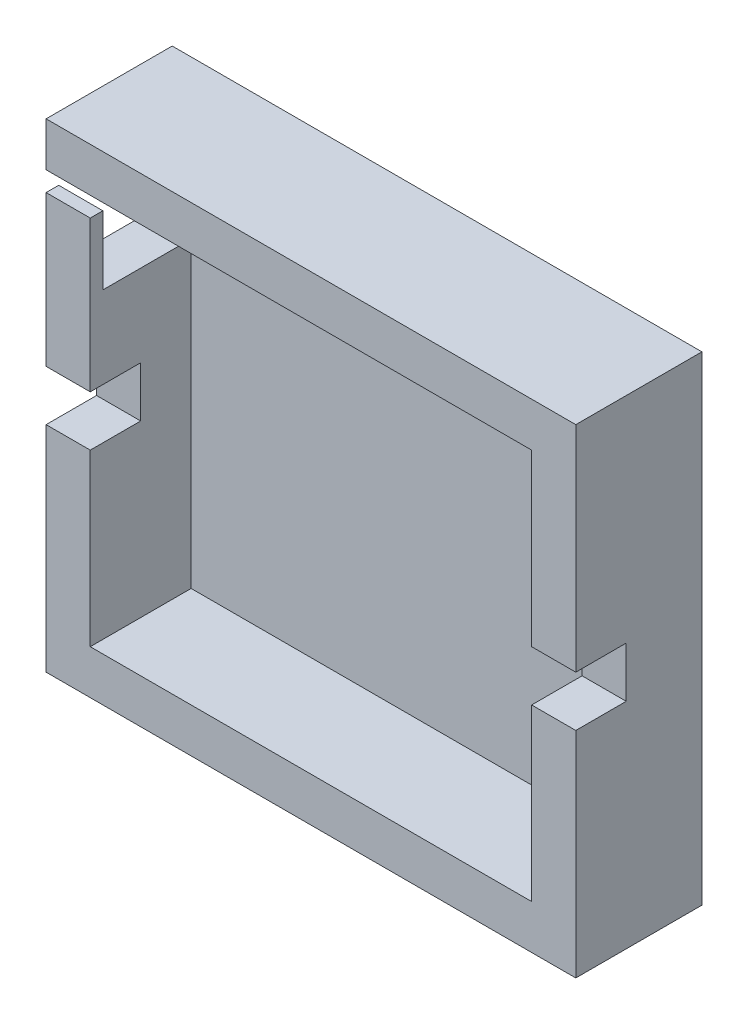
from build123d import *

# Parameters (mm, degrees)
SKETCH_1_W          = 42
SKETCH_1_H          = 38
EXTRUDE_1_DEPTH     = 2
SKETCH_2_W          = 42
SKETCH_2_H          = 38
SKETCH_2_W_2        = 35
SKETCH_2_H_2        = 31
EXTRUDE_2_DEPTH     = 8
SKETCH_3_W          = 1
SKETCH_3_H          = 1.564579438
CUT_EXTRUDE_1_DEPTH = 6.5
CUT_EXTRUDE_3_DEPTH = 4
SKETCH_7_W          = 23
SKETCH_7_H          = 4.2
CUT_EXTRUDE_4_DEPTH = 10


with BuildPart() as part:
    # 草图1 → 凸台-拉伸1 (new body)
    with BuildSketch(Plane.XY):
        with Locations((17.5, 15.5)):
            Rectangle(SKETCH_1_W, SKETCH_1_H)
    extrude(amount=EXTRUDE_1_DEPTH)

    # 草图2 → 凸台-拉伸2 (add)
    with BuildSketch(Plane.XY.offset(2)):
        with Locations((17.5, 15.5)):
            Rectangle(SKETCH_2_W, SKETCH_2_H)
        with Locations((17.5, 15.5)):
            Rectangle(SKETCH_2_W_2, SKETCH_2_H_2, mode=Mode.SUBTRACT)
    extrude(amount=EXTRUDE_2_DEPTH)

    # 草图3 → 切除-拉伸1 (cut)
    with BuildSketch(Plane.ZY.offset(3.5)):
        Polygon((9, 31), (2, 31), (2, 24), (9, 24), (9, 29.435420562), align=None)
        with Locations((9.5, 30.217710281)):
            Rectangle(SKETCH_3_W, SKETCH_3_H)
    extrude(amount=-CUT_EXTRUDE_1_DEPTH, mode=Mode.SUBTRACT)

    # 草图6 → 切除-拉伸3 (cut)
    with BuildSketch(Plane.XY.offset(10)):
        Polygon((0, 13.5), (0, 15.5), (0, 17.5), (-3.5, 17.5), (-3.5, 13.5), align=None)
        Polygon((35, 17.5), (35, 15.5), (35, 13.5), (38.5, 13.5), (38.5, 17.5), align=None)
    extrude(amount=-CUT_EXTRUDE_3_DEPTH, mode=Mode.SUBTRACT)

    # 草图7 → 切除-拉伸4 (cut)
    with BuildSketch(Plane(origin=(0, 0, 0), x_dir=(-1, 0, 0), z_dir=(0, 0, -1))):
        with Locations((-16.5, 26)):
            Rectangle(SKETCH_7_W, SKETCH_7_H)
    extrude(amount=-CUT_EXTRUDE_4_DEPTH, mode=Mode.SUBTRACT)


solid = part.part
